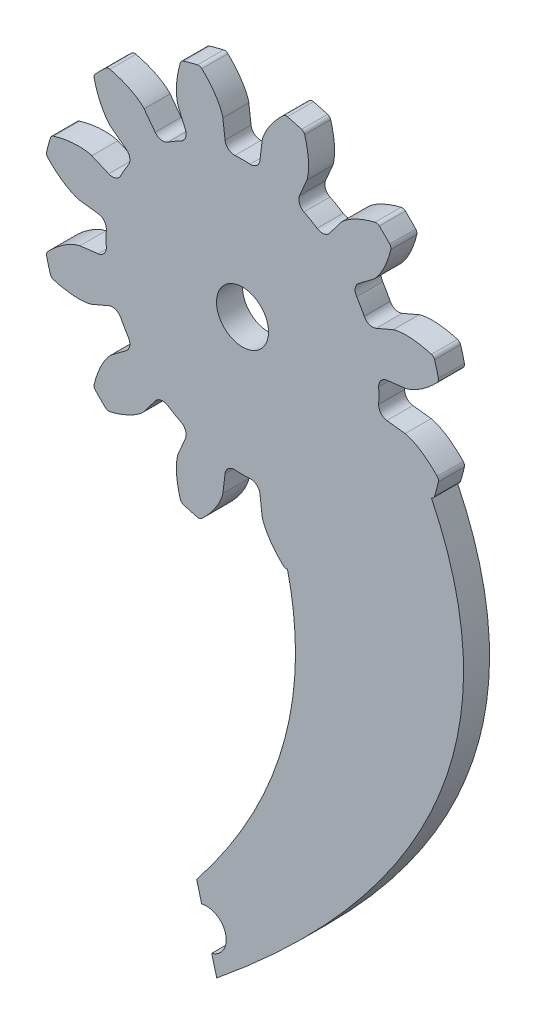
from build123d import *

# Parameters (mm, degrees)
SKETCH1_R                                 = 15.460869565
BOSS_EXTRUDE1_DEPTH                       = 2.00000108
CUT_EXTRUDE_DCLTBC_DEPTH                  = 3.00000108
FILLET_TIP_DCLTBC_R                       = 0.361402518
FILLET_ROOT_DCLTBC_R                      = 0.722805036
CIRPATTERN_DCLTBC_COUNT                   = 12
FILLET_TIP_DCLTBC_OF_CIRPATTERN_DCLTBC_R  = 0.361402518
FILLET_ROOT_DCLTBC_OF_CIRPATTERN_DCLTBC_R = 0.722805036
SKETCH5_R                                 = 2.00000108
CUT_EXTRUDE1_DEPTH                        = 2.000001
BOSS_EXTRUDE2_DEPTH                       = 2.000001


with BuildPart() as part:
    # Sketch1 → Boss-Extrude1 (new body)
    with BuildSketch(Plane.XY):
        Circle(SKETCH1_R)
    extrude(amount=BOSS_EXTRUDE1_DEPTH)

    # DCLTBC → Cut-Extrude-DCLTBC (cut, through all)
    with BuildSketch(Plane.XY):
        with BuildLine():
            Line((-1.510543322, 12.512719278), (-1.257387732, 10.415682551))
            ThreePointArc((-1.257387732, 10.415682551), (0, 10.491304348), (1.257387732, 10.415682551))
            Line((1.257387732, 10.415682551), (1.510543322, 12.512719278))
            add(Edge.make_bspline(
                [(1.510543322, 12.512719278), (1.511807207, 12.52162806), (1.515924555, 12.546526961), (1.525964996, 12.593225704), (1.545522882, 12.668734363), (1.575075918, 12.763809525), (1.618532671, 12.885167967), (1.676416598, 13.025962467), (1.746944184, 13.178158407), (1.831019865, 13.340745724), (1.921301743, 13.500101292), (2.017222693, 13.656232464), (2.118001385, 13.809089493), (2.246130211, 13.990900958), (2.408119815, 14.204131446), (2.609271975, 14.445920176), (2.851094426, 14.710982591), (3.051394448, 14.910653016), (3.189156504, 15.040748908), (3.26165246, 15.107161264), (3.266741108, 15.111812937)],
                knots=[0, 0, 0, 0, 0, 0.005376748, 0.015083688, 0.02853182, 0.046610139, 0.064854849, 0.092110525, 0.119476175, 0.146842495, 0.174208853, 0.201574955, 0.228941013, 0.256307345, 0.307035032, 0.361767351, 0.41649966, 0.471231936, 0.475358859, 0.475358859, 0.475358859, 0.475358859, 0.475358859], degree=4))
            ThreePointArc((3.266741108, 15.111812937), (0, 15.460869565), (-3.266741108, 15.111812937))
            add(Edge.make_bspline(
                [(-1.510543322, 12.512719278), (-1.511807207, 12.52162806), (-1.515924555, 12.546526961), (-1.525964996, 12.593225704), (-1.545522882, 12.668734363), (-1.575075918, 12.763809525), (-1.618532671, 12.885167967), (-1.676416598, 13.025962467), (-1.746944184, 13.178158407), (-1.831019865, 13.340745724), (-1.921301743, 13.500101292), (-2.017222693, 13.656232464), (-2.118001385, 13.809089493), (-2.246130211, 13.990900958), (-2.408119815, 14.204131446), (-2.609271975, 14.445920176), (-2.851094426, 14.710982591), (-3.051394448, 14.910653016), (-3.189156504, 15.040748908), (-3.26165246, 15.107161264), (-3.266741108, 15.111812937)],
                knots=[0, 0, 0, 0, 0, 0.005376748, 0.015083688, 0.02853182, 0.046610139, 0.064854849, 0.092110525, 0.119476175, 0.146842495, 0.174208853, 0.201574955, 0.228941013, 0.256307345, 0.307035032, 0.361767351, 0.41649966, 0.471231936, 0.475358859, 0.475358859, 0.475358859, 0.475358859, 0.475358859], degree=4))
        make_face()
    cut_extrude_dcltbc = extrude(amount=CUT_EXTRUDE_DCLTBC_DEPTH, mode=Mode.SUBTRACT)

    # Fillet-Tip-DCLTBC
    fillet_tip_dcltbc_edges = [part.edges().sort_by_distance(p)[0] for p in [
        (3.266741108, 15.111812937, 1.00000054),
        (-3.266741108, 15.111812937, 1.00000054),
    ]]
    fillet(fillet_tip_dcltbc_edges, radius=FILLET_TIP_DCLTBC_R)

    # Fillet-Root-DCLTBC
    fillet_root_dcltbc_edges = [part.edges().sort_by_distance(p)[0] for p in [
        (1.257387732, 10.415682551, 1.00000054),
        (-1.257387732, 10.415682551, 1.00000054),
    ]]
    fillet(fillet_root_dcltbc_edges, radius=FILLET_ROOT_DCLTBC_R)

    # CirPattern-DCLTBC: Cut-Extrude-DCLTBC ×12 about axis
    cirpattern_dcltbc_axis = Axis((0, 0, 2.00000108), (0, 0, 1))
    for i in range(1, CIRPATTERN_DCLTBC_COUNT):
        add(cut_extrude_dcltbc.rotate(cirpattern_dcltbc_axis, i * 360 / CIRPATTERN_DCLTBC_COUNT), mode=Mode.SUBTRACT)

    # Fillet-Tip-DCLTBC of CirPattern-DCLTBC
    fillet_tip_dcltbc_of_cirpattern_dcltbc_edges = [part.edges().sort_by_distance(p)[0] for p in [
        (-4.726825682, 14.720584455, 1.00000054),
        (-10.384987255, 11.453843347, 1.00000054),
        (-11.453843347, 10.384987255, 1.00000054),
        (-14.720584455, 4.726825682, 1.00000054),
        (-15.111812937, 3.266741108, 1.00000054),
        (-15.111812937, -3.266741108, 1.00000054),
        (-14.720584455, -4.726825682, 1.00000054),
        (-11.453843347, -10.384987255, 1.00000054),
        (-10.384987255, -11.453843347, 1.00000054),
        (-4.726825682, -14.720584455, 1.00000054),
        (-3.266741108, -15.111812937, 1.00000054),
        (3.266741108, -15.111812937, 1.00000054),
        (4.726825682, -14.720584455, 1.00000054),
        (10.384987255, -11.453843347, 1.00000054),
        (11.453843347, -10.384987255, 1.00000054),
        (14.720584455, -4.726825682, 1.00000054),
        (15.111812937, -3.266741108, 1.00000054),
        (15.111812937, 3.266741108, 1.00000054),
        (14.720584455, 4.726825682, 1.00000054),
        (11.453843347, 10.384987255, 1.00000054),
        (10.384987255, 11.453843347, 1.00000054),
        (4.726825682, 14.720584455, 1.00000054),
    ]]
    fillet(fillet_tip_dcltbc_of_cirpattern_dcltbc_edges, radius=FILLET_TIP_DCLTBC_OF_CIRPATTERN_DCLTBC_R)

    # Fillet-Root-DCLTBC of CirPattern-DCLTBC
    fillet_root_dcltbc_of_cirpattern_dcltbc_edges = [part.edges().sort_by_distance(p)[0] for p in [
        (-4.118911557, 9.648939553, 1.00000054),
        (-6.296770994, 8.391551821, 1.00000054),
        (-8.391551821, 6.296770994, 1.00000054),
        (-9.648939553, 4.118911557, 1.00000054),
        (-10.415682551, 1.257387732, 1.00000054),
        (-10.415682551, -1.257387732, 1.00000054),
        (-9.648939553, -4.118911557, 1.00000054),
        (-8.391551821, -6.296770994, 1.00000054),
        (-6.296770994, -8.391551821, 1.00000054),
        (-4.118911557, -9.648939553, 1.00000054),
        (-1.257387732, -10.415682551, 1.00000054),
        (1.257387732, -10.415682551, 1.00000054),
        (4.118911557, -9.648939553, 1.00000054),
        (6.296770994, -8.391551821, 1.00000054),
        (8.391551821, -6.296770994, 1.00000054),
        (9.648939553, -4.118911557, 1.00000054),
        (10.415682551, -1.257387732, 1.00000054),
        (10.415682551, 1.257387732, 1.00000054),
        (9.648939553, 4.118911557, 1.00000054),
        (8.391551821, 6.296770994, 1.00000054),
        (6.296770994, 8.391551821, 1.00000054),
        (4.118911557, 9.648939553, 1.00000054),
    ]]
    fillet(fillet_root_dcltbc_of_cirpattern_dcltbc_edges, radius=FILLET_ROOT_DCLTBC_OF_CIRPATTERN_DCLTBC_R)

    # Sketch5 → Cut-Extrude1 (cut)
    with BuildSketch(Plane.XY.offset(2.00000108)):
        Circle(SKETCH5_R)
    extrude(amount=-CUT_EXTRUDE1_DEPTH, mode=Mode.SUBTRACT)

    # Sketch9 → Boss-Extrude2 (add, through all)
    with BuildSketch(Plane.XY.offset(2.00000108)):
        with BuildLine():
            Line((8.726078806, -2.459810141), (2.208659998, -8.295503293))
            Line((2.208659998, -8.295503293), (9.097599581, -34.169662763))
            add(Edge.make_bspline(
                [(9.097599581, -34.169662763), (22.44119864, -17.702646885), (13.270688171, -2.459810141)],
                knots=[0.245675421, 0.245675421, 0.245675421, 1, 1, 1], degree=2))
            Line((13.270688171, -2.459810141), (8.726078806, -2.459810141))
        make_face()
        with BuildLine():
            Line((9.097599581, -34.169662763), (2.208659998, -8.295503293))
            Line((2.208659998, -8.295503293), (1.25506259, -9.149353878))
            add(Edge.make_bspline(
                [(-3.525993625, -39.227762732), (8.709972331, -23.749007607), (1.25506259, -9.149353878)],
                knots=[0, 0, 0, 1, 1, 1], degree=2))
            Line((-3.525993625, -39.227762732), (-3.140066438, -40.677266166))
            ThreePointArc((-3.140066438, -40.677266166), (-2.002077274, -40.828924162), (-1.304635816, -41.740842413))
            Line((-1.304635816, -41.740842413), (3.116649787, -40.563684584))
            add(Edge.make_bspline(
                [(3.116649787, -40.563684584), (6.525418824, -37.343929405), (9.097599581, -34.169662763)],
                knots=[0.100267937, 0.100267937, 0.100267937, 0.245675421, 0.245675421, 0.245675421], degree=2))
        make_face()
        with BuildLine():
            add(Edge.make_bspline(
                [(-1.982284876, -45.025776469), (0.766081373, -42.783915624), (3.116649787, -40.563684584)],
                knots=[0, 0, 0, 0.100267937, 0.100267937, 0.100267937], degree=2))
            Line((3.116649787, -40.563684584), (-1.304635816, -41.740842413))
            ThreePointArc((-1.304635816, -41.740842413), (-1.266816967, -41.932161214), (-1.254139251, -42.126769601))
            ThreePointArc((-1.254139251, -42.126769601), (-1.564834668, -43.040856363), (-2.368212063, -43.576273035))
            Line((-2.368212063, -43.576273035), (-1.982284876, -45.025776469))
        make_face()
    extrude(amount=-BOSS_EXTRUDE2_DEPTH)


solid = part.part
